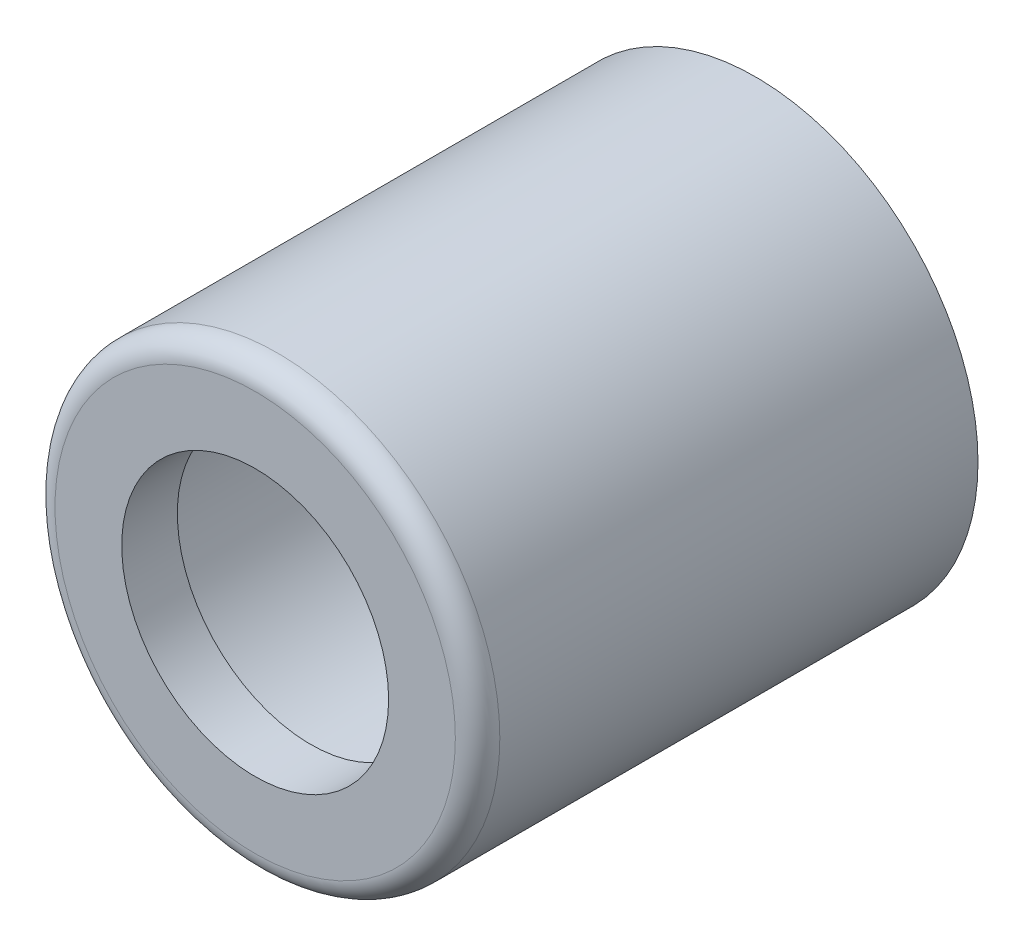
from build123d import *

# Parameters (mm, degrees)
SKETCH1_R           = 10
SKETCH1_R_2         = 7.5
BOSS_EXTRUDE1_DEPTH = 20
SKETCH2_R           = 10
BOSS_EXTRUDE2_DEPTH = 2.5
SKETCH3_R           = 6
CUT_EXTRUDE1_DEPTH  = 2.5
FILLET1_R           = 1


with BuildPart() as part:
    # Sketch1 → Boss-Extrude1 (new body)
    with BuildSketch(Plane.XY):
        Circle(SKETCH1_R)
        Circle(SKETCH1_R_2, mode=Mode.SUBTRACT)
    extrude(amount=BOSS_EXTRUDE1_DEPTH)

    # Sketch2 → Boss-Extrude2 (add)
    with BuildSketch(Plane.XY.offset(20)):
        Circle(SKETCH2_R)
    extrude(amount=BOSS_EXTRUDE2_DEPTH)

    # Sketch3 → Cut-Extrude1 (cut)
    with BuildSketch(Plane.XY.offset(22.5)):
        Circle(SKETCH3_R)
    extrude(amount=-CUT_EXTRUDE1_DEPTH, mode=Mode.SUBTRACT)

    # Fillet1
    fillet1_edges = [part.edges().sort_by_distance(p)[0] for p in [
        (-10, 0, 22.5),
    ]]
    fillet(fillet1_edges, radius=FILLET1_R)


solid = part.part
